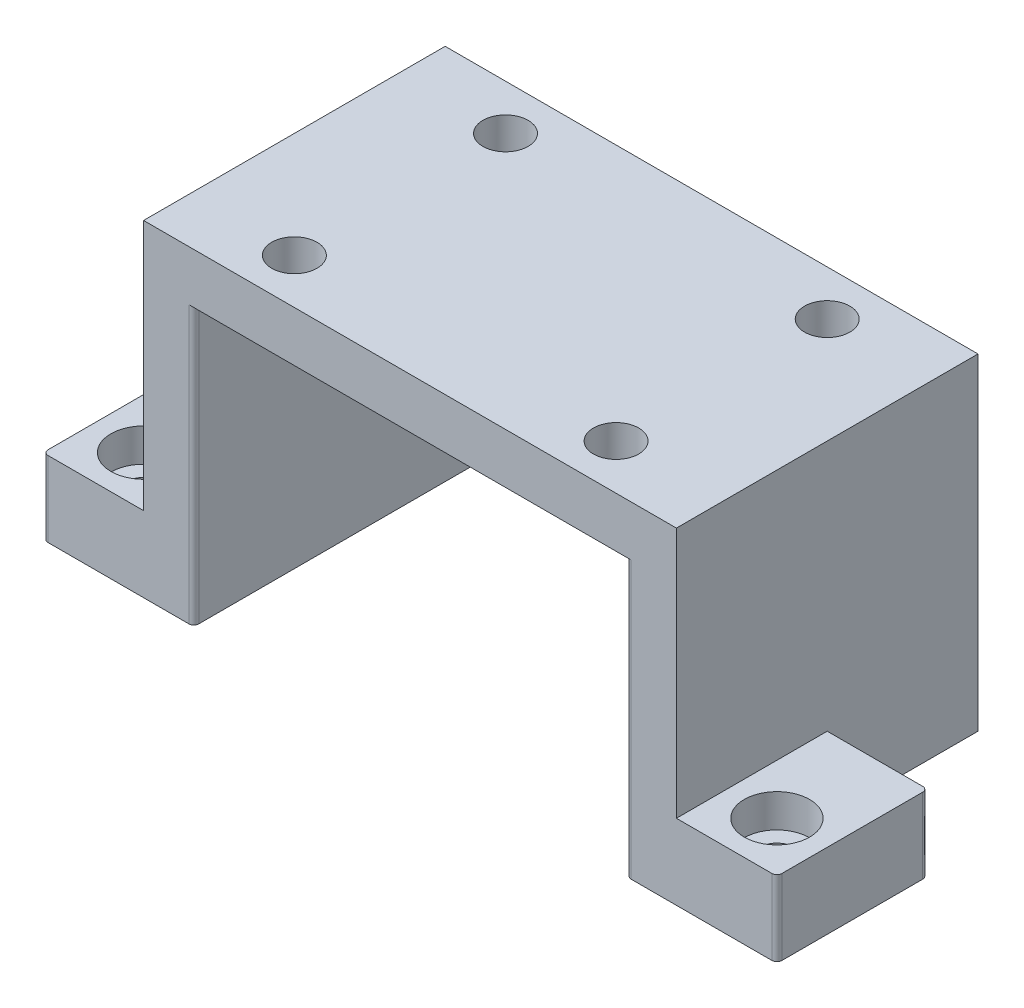
from build123d import *

# Parameters (mm, degrees)
SKETCH1_W           = 106
SKETCH1_H           = 60
BOSS_EXTRUDE1_DEPTH = 10
SKETCH2_W           = 10
SKETCH2_H           = 60
BOSS_EXTRUDE2_DEPTH = 55
SKETCH3_W           = 30
SKETCH3_H           = 15
BOSS_EXTRUDE3_DEPTH = 20
SKETCH4_W           = 60
SKETCH4_H           = 15
BOSS_EXTRUDE4_DEPTH = 20
SKETCH5_R           = 4.5
CUT_EXTRUDE1_DEPTH  = 66
SKETCH6_R           = 6.5
CUT_EXTRUDE2_DEPTH  = 6.6
SKETCH7_R           = 3.3
CUT_EXTRUDE3_DEPTH  = 9.4
FILLET1_R           = 1


with BuildPart() as part:
    # Sketch1 → Boss-Extrude1 (new body)
    with BuildSketch(Plane(origin=(0, 0, 0), x_dir=(1, 0, 0), z_dir=(0, 1, 0))):
        Rectangle(SKETCH1_W, SKETCH1_H)
    extrude(amount=BOSS_EXTRUDE1_DEPTH)

    # Sketch2 → Boss-Extrude2 (add)
    with BuildSketch(Plane.XZ):
        with Locations((-48, 0)):
            Rectangle(SKETCH2_W, SKETCH2_H)
        with Locations((48, 0)):
            Rectangle(SKETCH2_W, SKETCH2_H)
    extrude(amount=BOSS_EXTRUDE2_DEPTH)

    # Sketch3 → Boss-Extrude3 (add)
    with BuildSketch(Plane(origin=(53, 0, 0), x_dir=(0, 0, -1), z_dir=(1, 0, 0))):
        with Locations((-15, -47.5)):
            Rectangle(SKETCH3_W, SKETCH3_H)
    extrude(amount=BOSS_EXTRUDE3_DEPTH)

    # Sketch4 → Boss-Extrude4 (add)
    with BuildSketch(Plane.ZY.offset(53)):
        with Locations((0, -47.5)):
            Rectangle(SKETCH4_W, SKETCH4_H)
    extrude(amount=BOSS_EXTRUDE4_DEPTH)

    # Sketch5 → Cut-Extrude1 (cut, through all)
    with BuildSketch(Plane(origin=(0, 10, 0), x_dir=(1, 0, 0), z_dir=(0, 1, 0))):
        with Locations((-32, 21)):
            Circle(SKETCH5_R)
        with Locations((32, 21)):
            Circle(SKETCH5_R)
        with Locations((32, -21)):
            Circle(SKETCH5_R)
        with Locations((-32, -21)):
            Circle(SKETCH5_R)
    extrude(amount=-CUT_EXTRUDE1_DEPTH, mode=Mode.SUBTRACT)

    # Sketch6 → Cut-Extrude2 (cut)
    with BuildSketch(Plane(origin=(0, -40, 0), x_dir=(1, 0, 0), z_dir=(0, 1, 0))):
        with Locations((63, -20)):
            Circle(SKETCH6_R)
        with Locations((-63, 20)):
            Circle(SKETCH6_R)
        with Locations((-63, -20)):
            Circle(SKETCH6_R)
    extrude(amount=-CUT_EXTRUDE2_DEPTH, mode=Mode.SUBTRACT)

    # Sketch7 → Cut-Extrude3 (cut, through all)
    with BuildSketch(Plane(origin=(0, -46.6, 0), x_dir=(1, 0, 0), z_dir=(0, 1, 0))):
        with Locations((-63, 20)):
            Circle(SKETCH7_R)
        with Locations((-63, -20)):
            Circle(SKETCH7_R)
        with Locations((63, -20)):
            Circle(SKETCH7_R)
    extrude(amount=-CUT_EXTRUDE3_DEPTH, mode=Mode.SUBTRACT)

    # Fillet1
    fillet1_edges = [part.edges().sort_by_distance(p)[0] for p in [
        (-43, -27.5, -30),
        (-43, -27.5, 30),
        (43, -27.5, 30),
        (43, -27.5, -30),
        (73, -47.5, 30),
        (73, -47.5, 0),
        (-73, -47.5, -30),
        (-73, -47.5, 30),
    ]]
    fillet(fillet1_edges, radius=FILLET1_R)


solid = part.part
